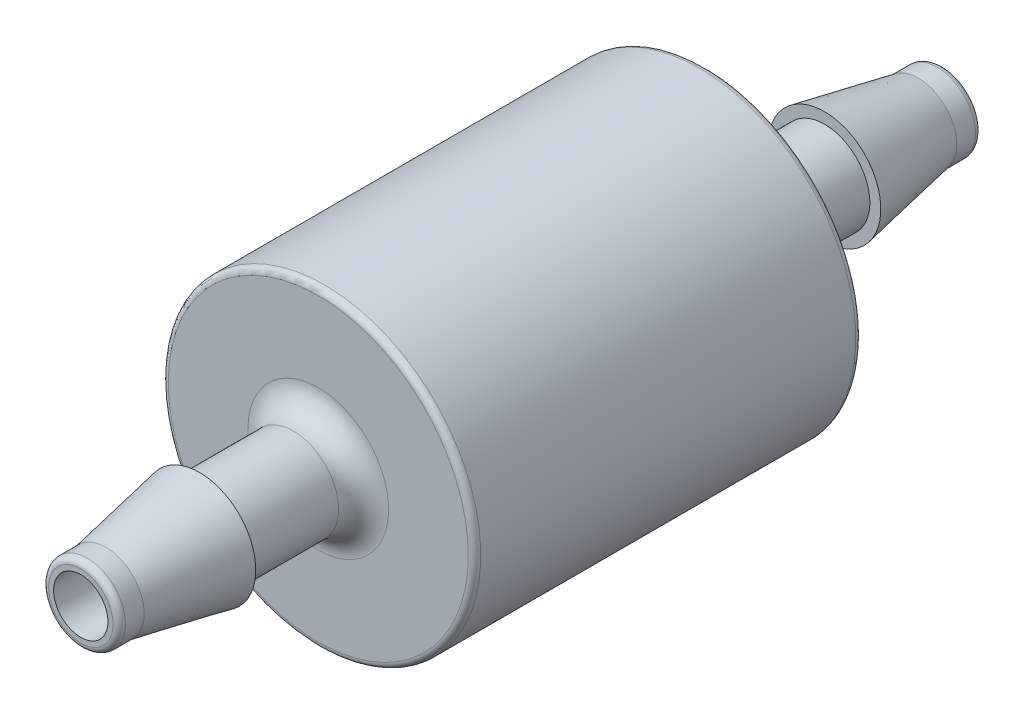
from build123d import *


with BuildPart() as part:
    # Sketch2 → Revolve1 (revolve)
    with BuildSketch(Plane(origin=(0, 0, 0), x_dir=(0, 0, -1), z_dir=(1, 0, 0)), mode=Mode.PRIVATE) as revolve1_sk:
        with BuildLine():
            Line((-17.526, 1.1049), (-17.526, 1.3081))
            ThreePointArc((-17.526, 1.3081), (-17.451605122, 1.487705122), (-17.272, 1.5621))
            Line((-17.272, 1.5621), (-16.51, 1.5621))
            Line((-16.51, 1.5621), (-12.7, 2.286))
            Line((-12.7, 2.286), (-12.7, 1.8415))
            Line((-12.7, 1.8415), (-8.89, 1.8415))
            ThreePointArc((-8.89, 1.8415), (-8.17157951, 2.13907951), (-7.874, 2.8575))
            Line((-7.874, 2.8575), (-7.874, 6.096))
            ThreePointArc((-7.874, 6.096), (-7.799605122, 6.275605122), (-7.62, 6.35))
            Line((-7.62, 6.35), (7.62, 6.35))
            ThreePointArc((7.62, 6.35), (7.799605122, 6.275605122), (7.874, 6.096))
            Line((7.874, 6.096), (7.874, 2.8575))
            ThreePointArc((7.874, 2.8575), (8.17157951, 2.13907951), (8.89, 1.8415))
            Line((8.89, 1.8415), (12.7, 1.8415))
            Line((12.7, 1.8415), (12.7, 2.286))
            Line((12.7, 2.286), (16.51, 1.5621))
            Line((16.51, 1.5621), (17.272, 1.5621))
            ThreePointArc((17.272, 1.5621), (17.451605122, 1.487705122), (17.526, 1.3081))
            Line((17.526, 1.3081), (17.526, 1.1049))
            Line((17.526, 1.1049), (-17.526, 1.1049))
        make_face()
    revolve(revolve1_sk.sketch.rotate(Axis((0, 0, -17.526), (0, 0, 1)), 90), axis=Axis((0, 0, -17.526), (0, 0, 1)))


solid = part.part
